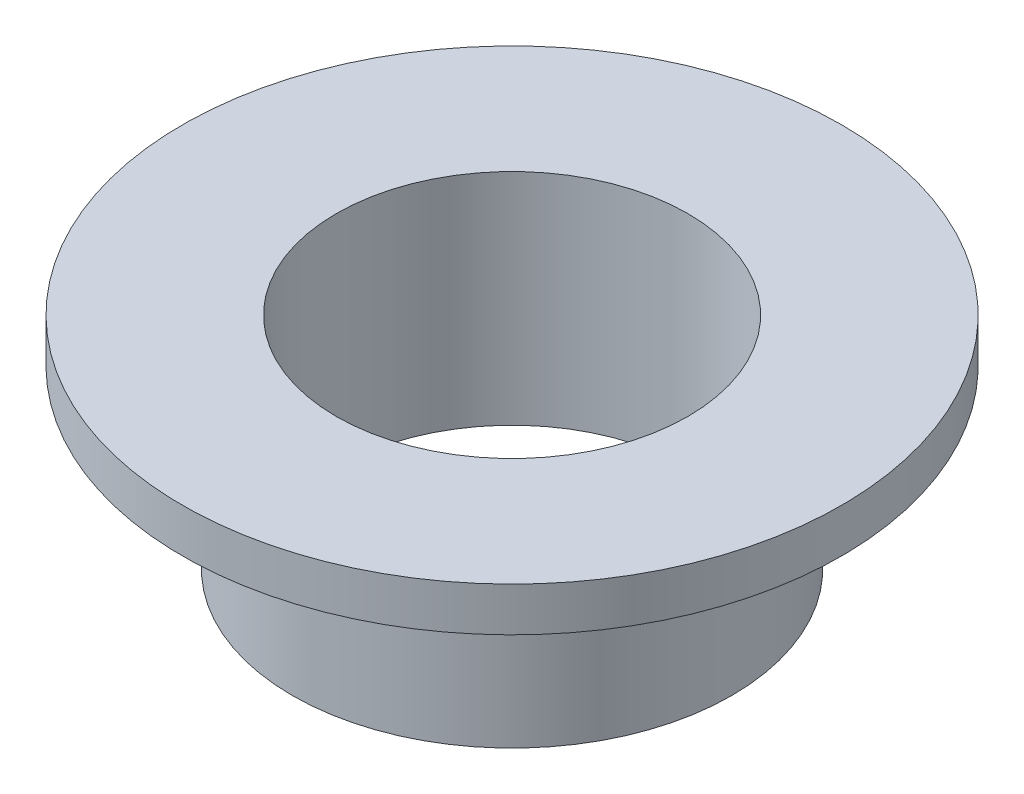
from build123d import *


with BuildPart() as part:
    # Esquisse1 → Révolution1 (revolve)
    with BuildSketch(Plane.XY):
        Polygon((-4, 5), (-7.5, 5), (-7.5, 4), (-5, 4), (-5, 0), (-4, 0), align=None)
    revolve(axis=Axis((0, 0, 0), (0, 1, 0)))


solid = part.part
